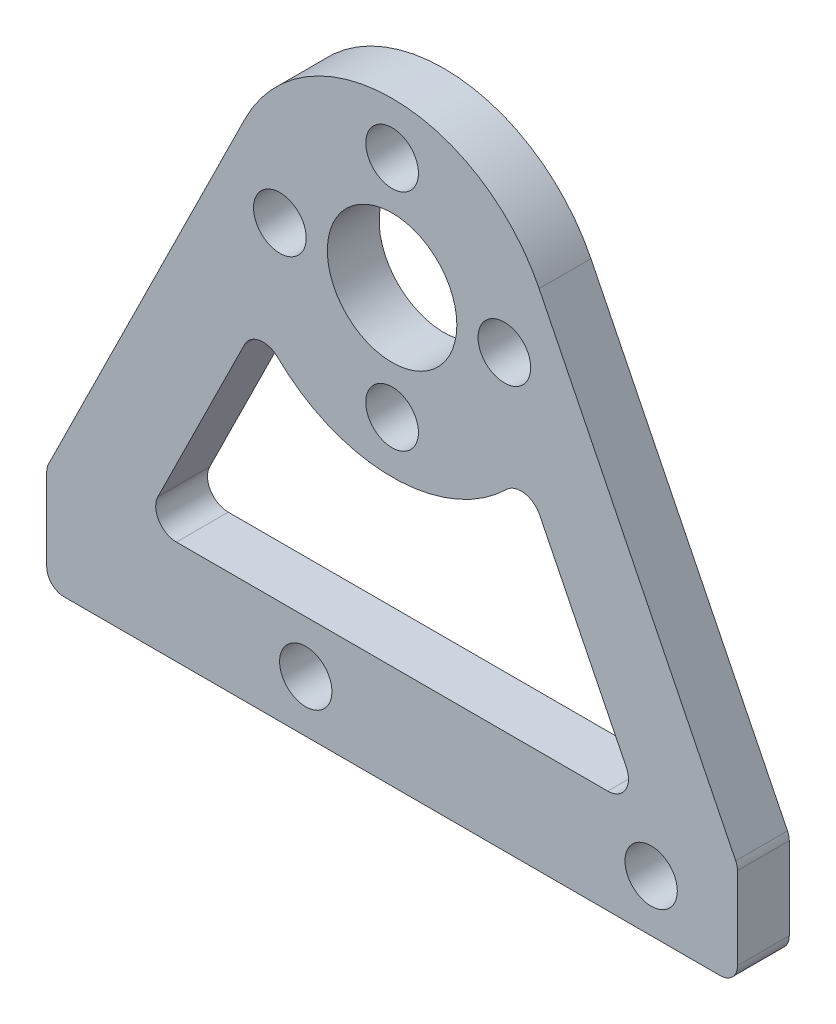
from build123d import *

# Parameters (mm, degrees)
SKETCH_1_R          = 1.525
SKETCH_1_R_2        = 3.75
EXTRUDE_1_DEPTH     = 3
FILLET_1_R          = 1
SKETCH_2_R          = 1.515
CUT_EXTRUDE_1_DEPTH = 10
CUT_EXTRUDE_2_DEPTH = 10
FILLET_2_R          = 1.2


with BuildPart() as part:
    # 草图1 → 凸台-拉伸1 (new body)
    with BuildSketch(Plane.XY):
        with BuildLine():
            Line((-20, -25), (20, -25))
            Line((20, -25), (20, -19))
            Line((20, -19), (8.514771251, 4.212917106))
            ThreePointArc((8.514771251, 4.212917106), (0, 9.5), (-8.514771251, 4.212917106))
            Line((-8.514771251, 4.212917106), (-20, -19))
            Line((-20, -19), (-20, -25))
        make_face()
        with Locations((0, 6.5)):
            Circle(SKETCH_1_R, mode=Mode.SUBTRACT)
        with Locations((6.5, 0)):
            Circle(SKETCH_1_R, mode=Mode.SUBTRACT)
        with Locations((0, -6.5)):
            Circle(SKETCH_1_R, mode=Mode.SUBTRACT)
        with Locations((-6.5, 0)):
            Circle(SKETCH_1_R, mode=Mode.SUBTRACT)
        Circle(SKETCH_1_R_2, mode=Mode.SUBTRACT)
    extrude(amount=EXTRUDE_1_DEPTH)

    # 圆角1
    fillet_1_edges = [part.edges().sort_by_distance(p)[0] for p in [
        (20, -25, 1.5),
        (-20, -25, 1.5),
        (-20, -19, 1.5),
        (20, -19, 1.5),
    ]]
    fillet(fillet_1_edges, radius=FILLET_1_R)

    # 草图2 → 切除-拉伸1 (cut)
    with BuildSketch(Plane(origin=(0, 0, 0), x_dir=(-1, 0, 0), z_dir=(0, 0, -1))):
        with Locations((-15, -22)):
            Circle(SKETCH_2_R)
        with Locations((5, -22)):
            Circle(SKETCH_2_R)
    extrude(amount=-CUT_EXTRUDE_1_DEPTH, mode=Mode.SUBTRACT)

    # 草图3 → 切除-拉伸2 (cut)
    with BuildSketch(Plane(origin=(0, 0, 0), x_dir=(-1, 0, 0), z_dir=(0, 0, -1))):
        with BuildLine():
            Line((-7.743606738, -5.50332215), (-14.421459062, -19))
            Line((-14.421459062, -19), (14.421459062, -19))
            Line((14.421459062, -19), (7.743606738, -5.50332215))
            ThreePointArc((7.743606738, -5.50332215), (0, -9.5), (-7.743606738, -5.50332215))
        make_face()
    extrude(amount=-CUT_EXTRUDE_2_DEPTH, mode=Mode.SUBTRACT)

    # 圆角2
    fillet_2_edges = [part.edges().sort_by_distance(p)[0] for p in [
        (7.743606738, -5.50332215, 1.5),
        (-7.743606738, -5.50332215, 1.5),
        (-14.421459062, -19, 1.5),
        (14.421459062, -19, 1.5),
    ]]
    fillet(fillet_2_edges, radius=FILLET_2_R)


solid = part.part
